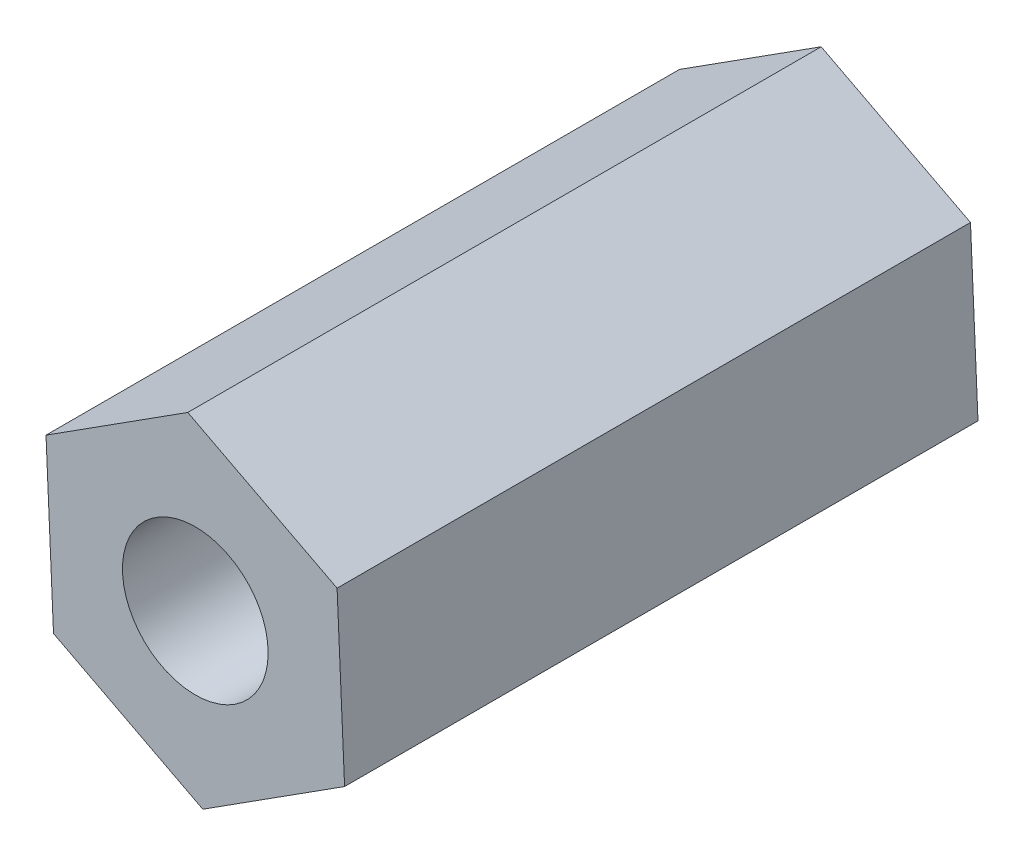
from build123d import *

# Parameters (mm, degrees)
SKETCH1_R           = 1.15
BOSS_EXTRUDE1_DEPTH = 10


with BuildPart() as part:
    # Sketch1 → Boss-Extrude1 (new body)
    with BuildSketch(Plane.XY):
        Polygon((2.357022055, -1.223838375), (2.23838615, 1.429321789), (-0.118635905, 2.653160164), (-2.357022055, 1.223838375), (-2.23838615, -1.429321789), (0.118635905, -2.653160164), align=None)
        Circle(SKETCH1_R, mode=Mode.SUBTRACT)
    extrude(amount=BOSS_EXTRUDE1_DEPTH)


solid = part.part
